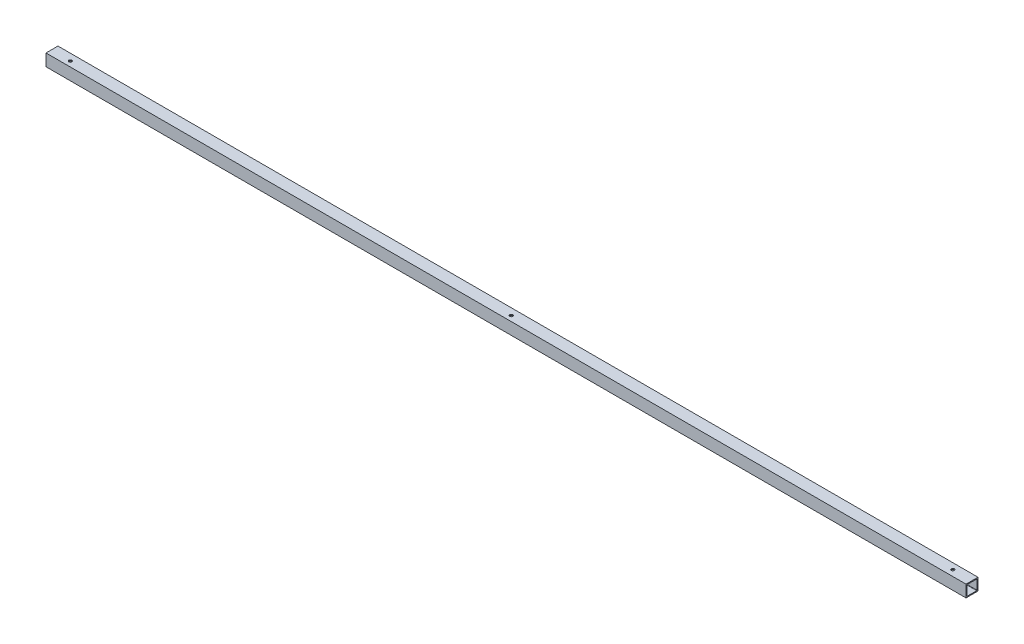
from build123d import *

# Parameters (mm, degrees)
SKETCH1_W           = 15.875
SKETCH1_H           = 15.875
BOSS_EXTRUDE1_DEPTH = 1219.2
SKETCH2_R           = 2
CUT_EXTRUDE1_DEPTH  = 16.875


with BuildPart() as part:
    # Sketch1 → Boss-Extrude1 (new body)
    with BuildSketch(Plane(origin=(0, 0, 0), x_dir=(0, 0, -1), z_dir=(1, 0, 0))):
        with Locations((7.9375, 7.9375)):
            Rectangle(SKETCH1_W, SKETCH1_H)
        with BuildLine():
            Line((1.7446, 1.2446), (14.1304, 1.2446))
            ThreePointArc((14.1304, 1.2446), (14.483953391, 1.391046609), (14.6304, 1.7446))
            Line((14.6304, 1.7446), (14.6304, 14.1304))
            ThreePointArc((14.6304, 14.1304), (14.483953391, 14.483953391), (14.1304, 14.6304))
            Line((14.1304, 14.6304), (1.7446, 14.6304))
            ThreePointArc((1.7446, 14.6304), (1.391046609, 14.483953391), (1.2446, 14.1304))
            Line((1.2446, 14.1304), (1.2446, 1.7446))
            ThreePointArc((1.2446, 1.7446), (1.391046609, 1.391046609), (1.7446, 1.2446))
        make_face(mode=Mode.SUBTRACT)
    extrude(amount=BOSS_EXTRUDE1_DEPTH)

    # Sketch2 → Cut-Extrude1 (cut, through all)
    with BuildSketch(Plane(origin=(0, 15.875, 0), x_dir=(1, 0, 0), z_dir=(0, 1, 0))):
        with Locations((609.600483099, 6.875)):
            Circle(SKETCH2_R)
        with Locations((25.4, 6.875)):
            Circle(SKETCH2_R)
        with Locations((1193.8, 7.9375)):
            Circle(SKETCH2_R)
    extrude(amount=-CUT_EXTRUDE1_DEPTH, mode=Mode.SUBTRACT)


solid = part.part
